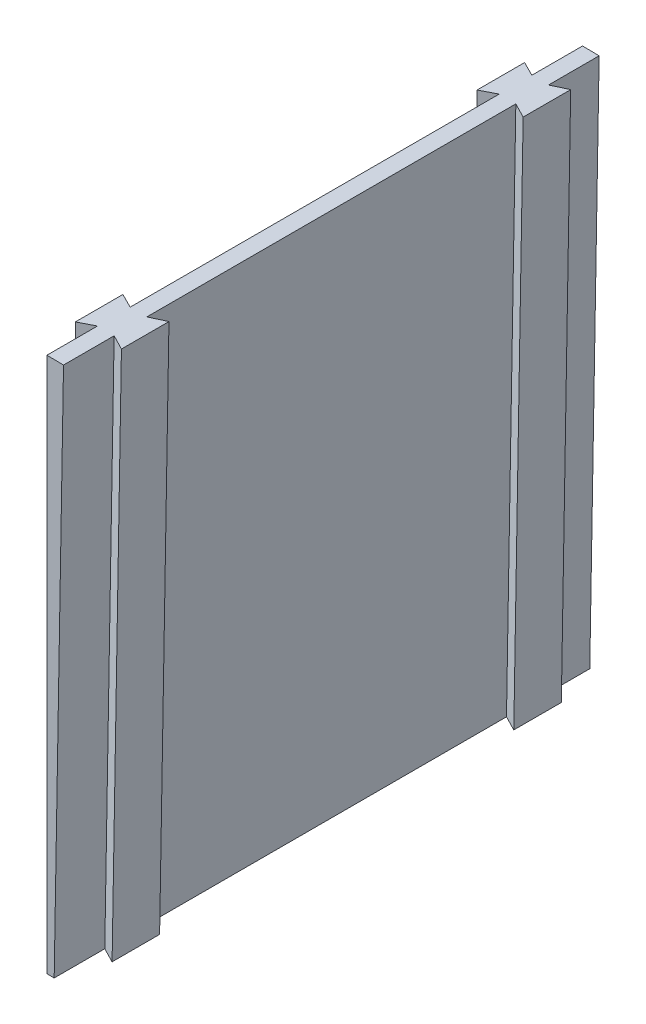
from build123d import *

# Parameters (mm, degrees)
BOSS_EXTRUDE1_DEPTH      = 101.6
BOSS_EXTRUDE2_REACH      = 145.704
BOSS_EXTRUDE2_END_RADIUS = 180.975
BOSS_EXTRUDE3_REACH      = 145.807
BOSS_EXTRUDE3_END_RADIUS = 180.975


with BuildPart() as part:
    # Sketch1 → Boss-Extrude1 (new body)
    with BuildSketch(Plane.XY):
        with BuildLine():
            Line((0, 79.375), (0, 180.975))
            ThreePointArc((0, 180.975), (1.579284762, 180.968109027), (3.158449255, 180.947436631))
            Line((3.158449255, 180.947436631), (1.385284761, 79.362910803))
            ThreePointArc((1.385284761, 79.362910803), (0.692668755, 79.371977643), (0, 79.375))
        make_face()
    extrude(amount=BOSS_EXTRUDE1_DEPTH)

    # Boss-Extrude2: up to this cylinder (the profile starts inside it)
    boss_extrude2_end = Plane(origin=(0, 0, 50.8), z_dir=(0, 0, -1)) * Cylinder(BOSS_EXTRUDE2_END_RADIUS, 730.558, mode=Mode.PRIVATE)
    # Sketch2 → Boss-Extrude2 (add, up to the surface)
    with BuildSketch(Plane(origin=(1.385284761, 79.362910803, 0), x_dir=(0, 0, -1), z_dir=(-0.017452406437283553, -0.9998476951563913, 0)), mode=Mode.PRIVATE) as boss_extrude2_sk1:
        Polygon((-92.000208065, 0), (-93.4085, 2.794), (-84.3915, 2.794), (-85.799791935, 0), align=None)
    boss_extrude2_tool1 = extrude(boss_extrude2_sk1.sketch, amount=-BOSS_EXTRUDE2_REACH, mode=Mode.PRIVATE) & boss_extrude2_end
    add(boss_extrude2_tool1.solids().sort_by_distance((2.868249, 79.337026, 88.9))[0])
    # Sketch2 → Boss-Extrude2 (add, up to the surface)
    with BuildSketch(Plane(origin=(1.385284761, 79.362910803, 0), x_dir=(0, 0, -1), z_dir=(-0.017452406437283553, -0.9998476951563913, 0)), mode=Mode.PRIVATE) as boss_extrude2_sk2:
        Polygon((-15.800208065, 0), (-9.599791935, 0), (-8.1915, 2.794), (-17.2085, 2.794), align=None)
    boss_extrude2_tool2 = extrude(boss_extrude2_sk2.sketch, amount=-BOSS_EXTRUDE2_REACH, mode=Mode.PRIVATE) & boss_extrude2_end
    add(boss_extrude2_tool2.solids().sort_by_distance((2.868249, 79.337026, 12.7))[0])

    # Boss-Extrude3: up to this cylinder (the profile starts inside it)
    boss_extrude3_end = Plane(origin=(0, 0, 50.8), z_dir=(0, 0, -1)) * Cylinder(BOSS_EXTRUDE3_END_RADIUS, 730.764, mode=Mode.PRIVATE)
    # Sketch3 → Boss-Extrude3 (add, up to the surface)
    with BuildSketch(Plane(origin=(0, 79.375, 0), x_dir=(0, 0, -1), z_dir=(0, -1, 0)), mode=Mode.PRIVATE) as boss_extrude3_sk1:
        Polygon((-92.000208065, 0), (-93.4085, -2.79357446), (-84.3915, -2.79357446), (-85.799791935, 0), align=None)
    boss_extrude3_tool1 = extrude(boss_extrude3_sk1.sketch, amount=-BOSS_EXTRUDE3_REACH, mode=Mode.PRIVATE) & boss_extrude3_end
    add(boss_extrude3_tool1.solids().sort_by_distance((-1.482964, 79.375, 88.9))[0])
    # Sketch3 → Boss-Extrude3 (add, up to the surface)
    with BuildSketch(Plane(origin=(0, 79.375, 0), x_dir=(0, 0, -1), z_dir=(0, -1, 0)), mode=Mode.PRIVATE) as boss_extrude3_sk2:
        Polygon((-15.800208065, 0), (-9.599791935, 0), (-8.1915, -2.79357446), (-17.2085, -2.79357446), align=None)
    boss_extrude3_tool2 = extrude(boss_extrude3_sk2.sketch, amount=-BOSS_EXTRUDE3_REACH, mode=Mode.PRIVATE) & boss_extrude3_end
    add(boss_extrude3_tool2.solids().sort_by_distance((-1.482964, 79.375, 12.7))[0])


solid = part.part
